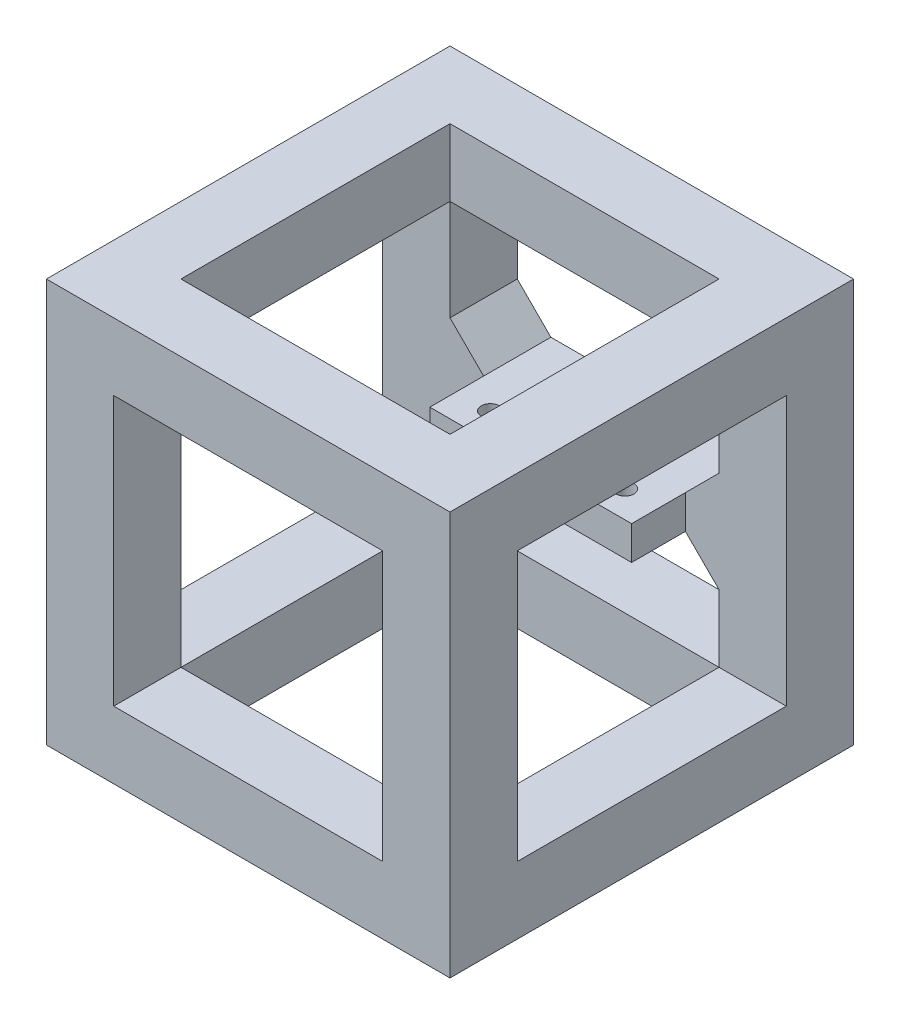
from build123d import *

# Parameters (mm, degrees)
SKETCH_1_W           = 30
SKETCH_1_H           = 18
SKETCH_1_R           = 1.35
EXTRUDE_1_DEPTH      = 5
SKETCH_2_W           = 60
SKETCH_2_H           = 60
SKETCH_2_W_2         = 40
SKETCH_2_H_2         = 40
EXTRUDE_2_DEPTH      = 30
EXTRUDE_2_DEPTH_BACK = 30
SKETCH_3_W           = 40
SKETCH_3_H           = 40
CUT_EXTRUDE_1_DEPTH  = 10
SKETCH_4_W           = 40
SKETCH_4_H           = 40
CUT_EXTRUDE_2_DEPTH  = 10
SKETCH_5_W           = 40
SKETCH_5_H           = 40
CUT_EXTRUDE_3_DEPTH  = 10
SKETCH_6_W           = 40
SKETCH_6_H           = 20
SKETCH_6_H_2         = 15
CUT_EXTRUDE_4_DEPTH  = 10
CHAMFER_1_SIZE       = 5


with BuildPart() as part:
    # 스케치1 → 보스-돌출1 (new body)
    with BuildSketch(Plane(origin=(0, 0, 0), x_dir=(1, 0, 0), z_dir=(0, 1, 0))):
        with Locations((0, 5)):
            Rectangle(SKETCH_1_W, SKETCH_1_H)
        with Locations((-10, 0)):
            Circle(SKETCH_1_R, mode=Mode.SUBTRACT)
        with Locations((10, 0)):
            Circle(SKETCH_1_R, mode=Mode.SUBTRACT)
    extrude(amount=EXTRUDE_1_DEPTH)

    # 스케치2 → 보스-돌출2 (add, two sides)
    with BuildSketch(Plane(origin=(0, 5, 0), x_dir=(1, 0, 0), z_dir=(0, 1, 0))) as extrude_2_sk:
        with Locations((0, -16)):
            Rectangle(SKETCH_2_W, SKETCH_2_H)
        with Locations((0, -16)):
            Rectangle(SKETCH_2_W_2, SKETCH_2_H_2, mode=Mode.SUBTRACT)
    extrude(amount=EXTRUDE_2_DEPTH)
    extrude(extrude_2_sk.sketch, amount=-EXTRUDE_2_DEPTH_BACK)

    # 스케치3 → 컷-돌출1 (cut)
    with BuildSketch(Plane.XY.offset(46)):
        with Locations((0, 5)):
            Rectangle(SKETCH_3_W, SKETCH_3_H)
    extrude(amount=-CUT_EXTRUDE_1_DEPTH, mode=Mode.SUBTRACT)

    # 스케치4 → 컷-돌출2 (cut)
    with BuildSketch(Plane.ZY.offset(30)):
        with Locations((16, 5)):
            Rectangle(SKETCH_4_W, SKETCH_4_H)
    extrude(amount=-CUT_EXTRUDE_2_DEPTH, mode=Mode.SUBTRACT)

    # 스케치5 → 컷-돌출3 (cut)
    with BuildSketch(Plane(origin=(30, 0, 0), x_dir=(0, 0, -1), z_dir=(1, 0, 0))):
        with Locations((-16, 5)):
            Rectangle(SKETCH_5_W, SKETCH_5_H)
    extrude(amount=-CUT_EXTRUDE_3_DEPTH, mode=Mode.SUBTRACT)

    # 스케치6 → 컷-돌출4 (cut)
    with BuildSketch(Plane.XY.offset(-4)):
        with Locations((0, 15)):
            Rectangle(SKETCH_6_W, SKETCH_6_H)
        with Locations((0, -7.5)):
            Rectangle(SKETCH_6_W, SKETCH_6_H_2)
    extrude(amount=-CUT_EXTRUDE_4_DEPTH, mode=Mode.SUBTRACT)

    # 모따기1
    chamfer_1_edges = [part.edges().sort_by_distance(p)[0] for p in [
        (20, 5, -9),
        (-20, 5, -9),
        (-20, 0, -9),
        (20, 0, -9),
    ]]
    chamfer(chamfer_1_edges, length=CHAMFER_1_SIZE)


solid = part.part
